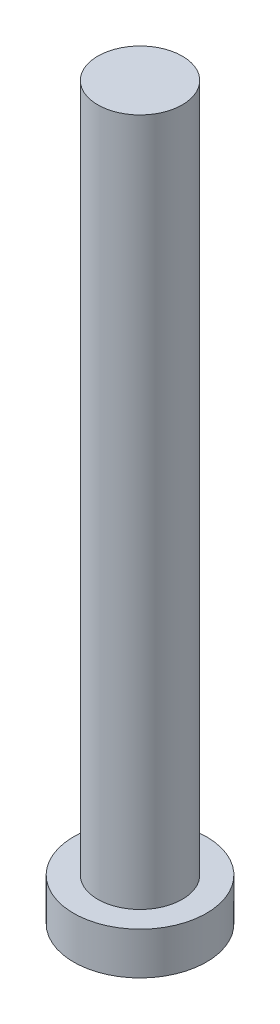
from build123d import *


with BuildPart() as part:
    # Esboço1 → Revolução1 (revolve)
    with BuildSketch(Plane.XY, mode=Mode.PRIVATE) as revolu_o1_sk:
        Polygon((0, 121), (7, 121), (7, 7), (11, 7), (11, 0), (0, 0), align=None)
    revolve(revolu_o1_sk.sketch.rotate(Axis((0, 0, 0), (0, 1, 0)), 90), axis=Axis((0, 0, 0), (0, 1, 0)))  # turned: the seam where the file's is


solid = part.part
